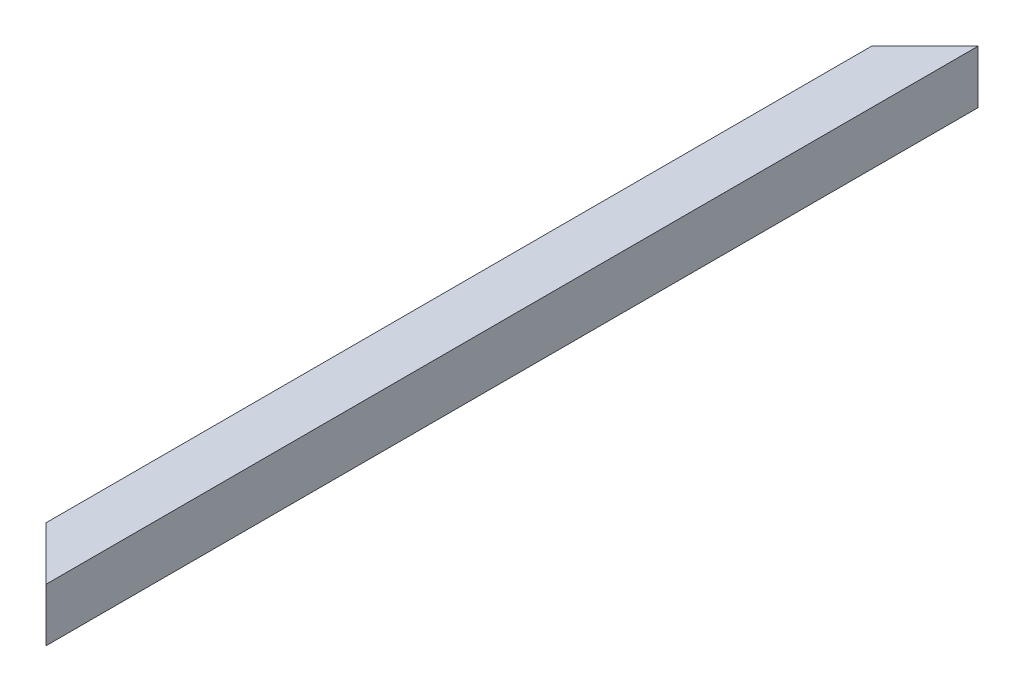
from build123d import *

# Parameters (mm, degrees)
SKETCH1_W          = 40
SKETCH1_H          = 40
SKETCH1_W_2        = 32
SKETCH1_H_2        = 32
CUT_EXTRUDE1_DEPTH = 41.0000001


with BuildPart() as part:
    # Sweep1: sweep along a curve in space
    with BuildLine() as sweep1_path:
        add(Edge.make_bspline(
            [(0, 0, 0), (0, 0, 700)],
            knots=[0, 0, 1, 1], degree=1))
    # Sketch1 → Sweep1 (sweep)
    with BuildSketch(Plane.XY):
        Rectangle(SKETCH1_W, SKETCH1_H)
        Rectangle(SKETCH1_W_2, SKETCH1_H_2, mode=Mode.SUBTRACT)
    sweep(path=sweep1_path.line)

    # Sketch2 → Cut-Extrude1 (cut, through all)
    with BuildSketch(Plane(origin=(0, 20, 0), x_dir=(1, 0, 0), z_dir=(0, 1, 0))):
        Polygon((20, 0), (-20, -40), (-20, 0), align=None)
        Polygon((20, -700), (-20, -660), (-20, -700), align=None)
    extrude(amount=-CUT_EXTRUDE1_DEPTH, mode=Mode.SUBTRACT)


solid = part.part
